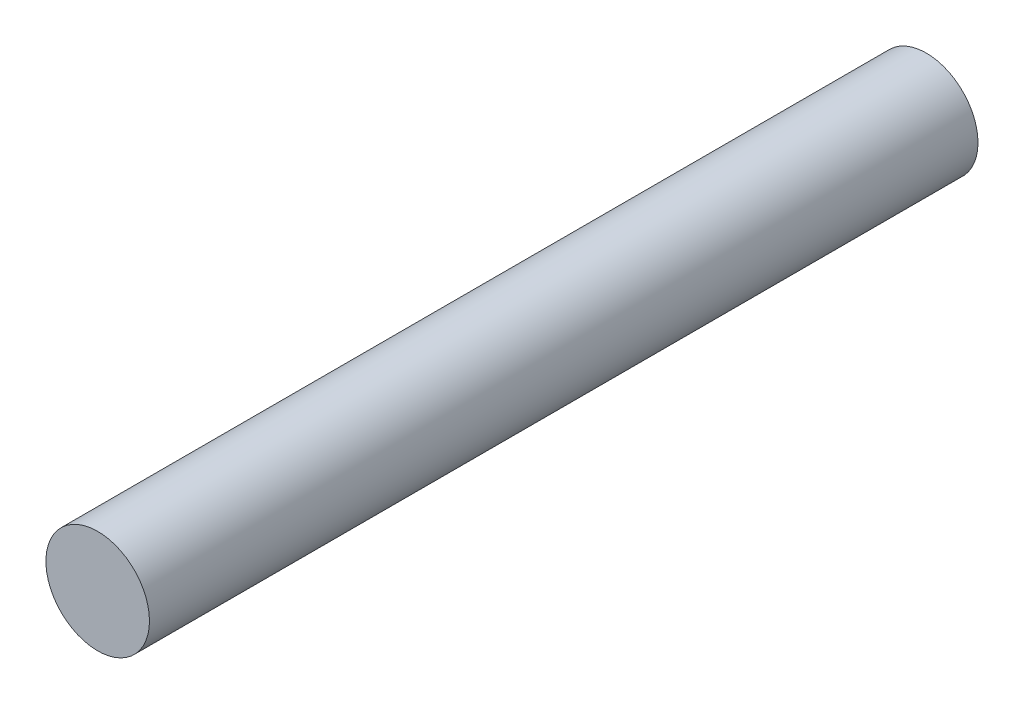
from build123d import *

# Parameters (mm, degrees)
SKETCH1_R        = 3.175
EXTRUSION1_DEPTH = 50.8


with BuildPart() as part:
    # Sketch1 → Extrusion1 (new body)
    with BuildSketch(Plane.XY):
        Circle(SKETCH1_R)
    extrude(amount=EXTRUSION1_DEPTH)


solid = part.part
